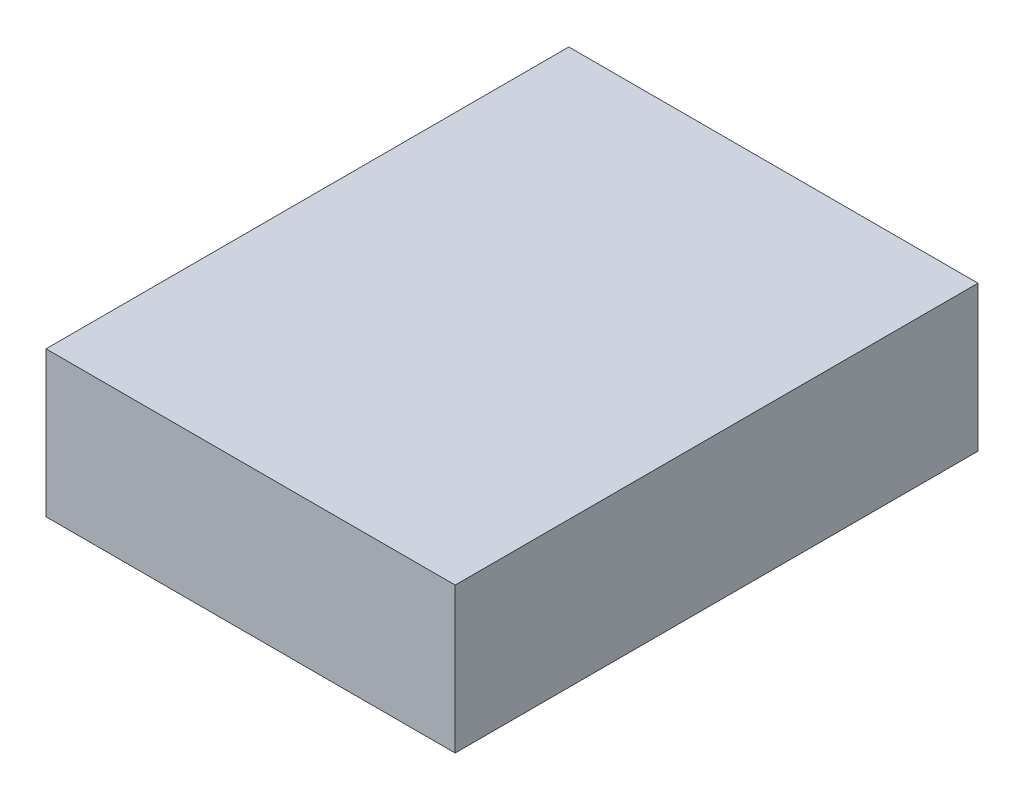
from build123d import *

# Parameters (mm, degrees)
SKETCH1_W           = 90
SKETCH1_H           = 115
BOSS_EXTRUDE1_DEPTH = 32


with BuildPart() as part:
    # Sketch1 → Boss-Extrude1 (new body)
    with BuildSketch(Plane(origin=(0, 0, 0), x_dir=(1, 0, 0), z_dir=(0, 1, 0))):
        Rectangle(SKETCH1_W, SKETCH1_H)
    extrude(amount=BOSS_EXTRUDE1_DEPTH)


solid = part.part
